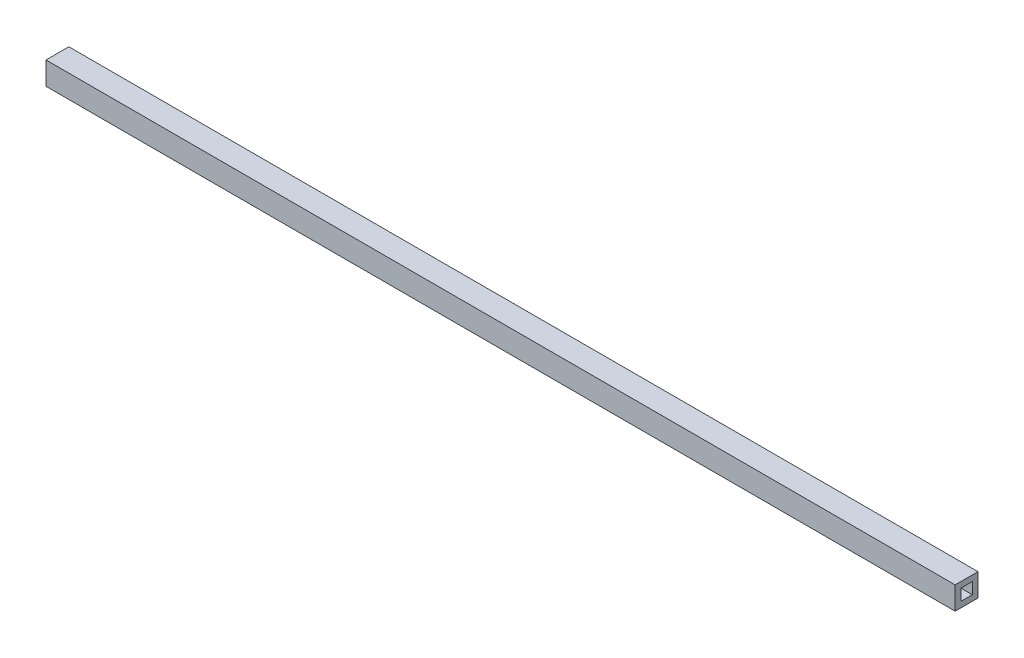
from build123d import *

# Parameters (mm, degrees)
SKETCH1_W           = 20
SKETCH1_H           = 20
BOSS_EXTRUDE1_DEPTH = 796
SKETCH3_W           = 10
SKETCH3_H           = 10
CUT_EXTRUDE1_DEPTH  = 10
SKETCH4_W           = 10
SKETCH4_H           = 10
CUT_EXTRUDE2_DEPTH  = 10


with BuildPart() as part:
    # Sketch1 → Boss-Extrude1 (new body)
    with BuildSketch(Plane(origin=(0, 0, 0), x_dir=(0, 0, -1), z_dir=(1, 0, 0))):
        Rectangle(SKETCH1_W, SKETCH1_H)
    extrude(amount=BOSS_EXTRUDE1_DEPTH)

    # Sketch3 → Cut-Extrude1 (cut)
    with BuildSketch(Plane(origin=(796, 0, 0), x_dir=(0, 0, -1), z_dir=(1, 0, 0))):
        Rectangle(SKETCH3_W, SKETCH3_H)
    extrude(amount=-CUT_EXTRUDE1_DEPTH, mode=Mode.SUBTRACT)

    # Sketch4 → Cut-Extrude2 (cut)
    with BuildSketch(Plane.ZY):
        Rectangle(SKETCH4_W, SKETCH4_H)
    extrude(amount=-CUT_EXTRUDE2_DEPTH, mode=Mode.SUBTRACT)


solid = part.part
